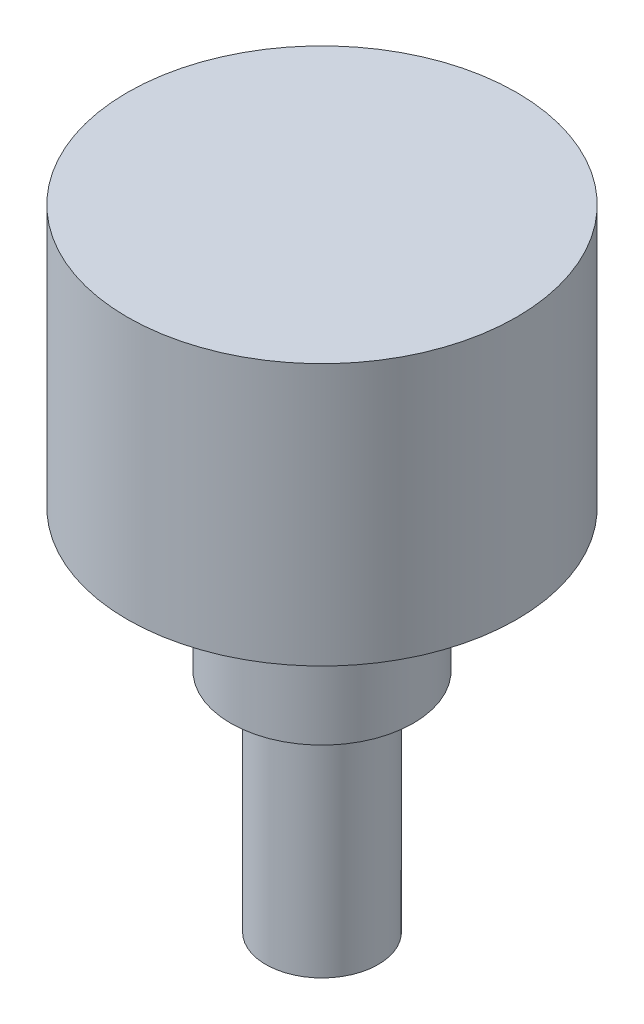
from build123d import *

# Parameters (mm, degrees)
SKETCH1_R           = 11
BOSS_EXTRUDE1_DEPTH = 14.8
SKETCH2_R           = 5.16
BOSS_EXTRUDE2_DEPTH = 8
SKETCH3_R           = 3.175
BOSS_EXTRUDE3_DEPTH = 12.8
SKETCH4_R           = 0.75
BOSS_EXTRUDE4_DEPTH = 2.1


with BuildPart() as part:
    # Sketch1 → Boss-Extrude1 (new body)
    with BuildSketch(Plane(origin=(0, 0, 0), x_dir=(1, 0, 0), z_dir=(0, 1, 0))):
        Circle(SKETCH1_R)
    extrude(amount=BOSS_EXTRUDE1_DEPTH)

    # Sketch2 → Boss-Extrude2 (add)
    with BuildSketch(Plane.XZ):
        Circle(SKETCH2_R)
    extrude(amount=BOSS_EXTRUDE2_DEPTH)

    # Sketch3 → Boss-Extrude3 (add)
    with BuildSketch(Plane(origin=(0, -8, 0), x_dir=(-1, 0, 0), z_dir=(0, -1, 0))):
        Circle(SKETCH3_R)
    extrude(amount=BOSS_EXTRUDE3_DEPTH)

    # Sketch4 → Boss-Extrude4 (add)
    with BuildSketch(Plane.XZ):
        with Locations((7.9, 0)):
            Circle(SKETCH4_R)
    extrude(amount=BOSS_EXTRUDE4_DEPTH)


solid = part.part
